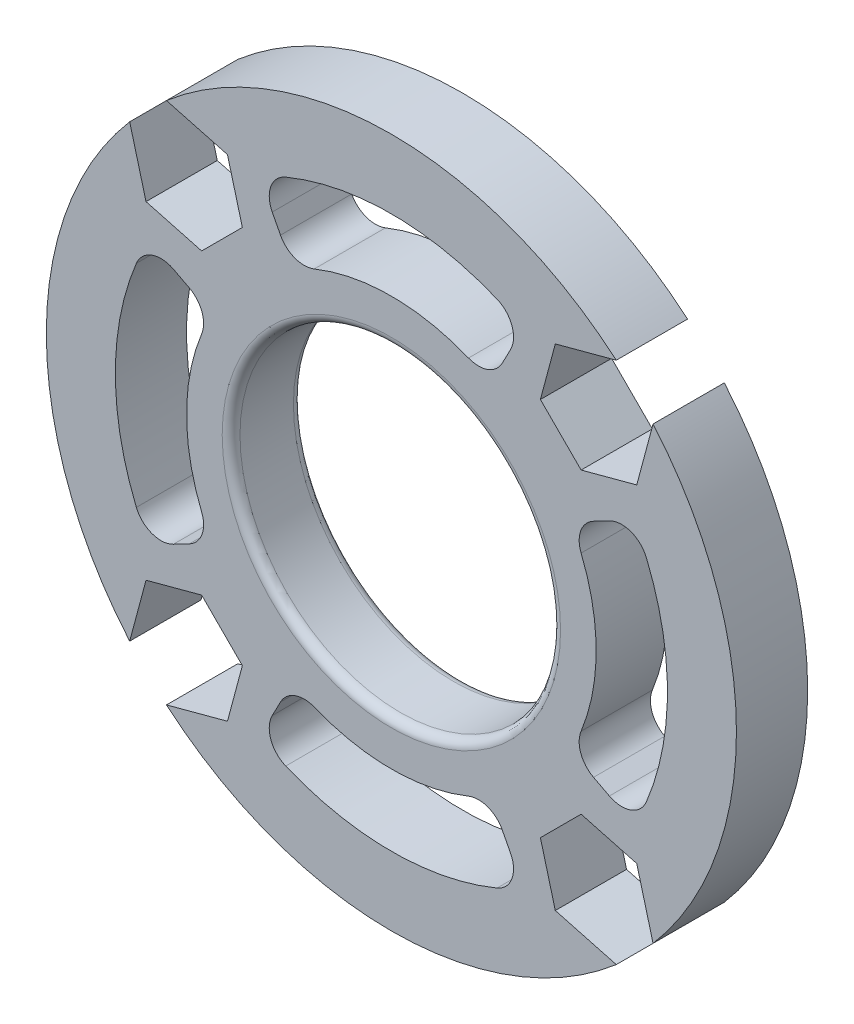
from build123d import *

# Parameters (mm, degrees)
SKETCH1_R           = 19.375
SKETCH1_R_2         = 9
BOSS_EXTRUDE1_DEPTH = 4
CUT_EXTRUDE1_DEPTH  = 4
FILLET1_R           = 0.5
CUT_EXTRUDE2_DEPTH  = 10


with BuildPart() as part:
    # Sketch1 → Boss-Extrude1 (new body)
    with BuildSketch(Plane.XY):
        Circle(SKETCH1_R)
        Circle(SKETCH1_R_2, mode=Mode.SUBTRACT)
        with BuildLine():
            Line((6.689691504, 12.241024694), (6.226047976, 11.350373764))
            ThreePointArc((6.226047976, 11.350373764), (5.41320923, 10.635157913), (4.330662681, 10.653420143))
            ThreePointArc((4.330662681, 10.653420143), (0, 11.5), (-4.330662681, 10.653420143))
            ThreePointArc((-4.330662681, 10.653420143), (-5.41320923, 10.635157913), (-6.226047976, 11.350373764))
            Line((-6.226047976, 11.350373764), (-6.689691504, 12.241024694))
            ThreePointArc((-6.689691504, 12.241024694), (-6.768746058, 13.446590252), (-5.933372603, 14.319395572))
            ThreePointArc((-5.933372603, 14.319395572), (0, 15.5), (5.933372603, 14.319395572))
            ThreePointArc((5.933372603, 14.319395572), (6.768746058, 13.446590252), (6.689691504, 12.241024694))
        make_face(mode=Mode.SUBTRACT)
        with BuildLine():
            Line((12.241024694, 6.689691504), (11.350373764, 6.226047976))
            ThreePointArc((11.350373764, 6.226047976), (10.635157913, 5.41320923), (10.653420143, 4.330662681))
            ThreePointArc((10.653420143, 4.330662681), (11.5, 0), (10.653420143, -4.330662681))
            ThreePointArc((10.653420143, -4.330662681), (10.635157913, -5.41320923), (11.350373764, -6.226047976))
            Line((11.350373764, -6.226047976), (12.241024694, -6.689691504))
            ThreePointArc((12.241024694, -6.689691504), (13.446590252, -6.768746058), (14.319395572, -5.933372603))
            ThreePointArc((14.319395572, -5.933372603), (15.5, 0), (14.319395572, 5.933372603))
            ThreePointArc((14.319395572, 5.933372603), (13.446590252, 6.768746058), (12.241024694, 6.689691504))
        make_face(mode=Mode.SUBTRACT)
        with BuildLine():
            Line((6.689691504, -12.241024694), (6.226047976, -11.350373764))
            ThreePointArc((6.226047976, -11.350373764), (5.41320923, -10.635157913), (4.330662681, -10.653420143))
            ThreePointArc((4.330662681, -10.653420143), (0, -11.5), (-4.330662681, -10.653420143))
            ThreePointArc((-4.330662681, -10.653420143), (-5.41320923, -10.635157913), (-6.226047976, -11.350373764))
            Line((-6.226047976, -11.350373764), (-6.689691504, -12.241024694))
            ThreePointArc((-6.689691504, -12.241024694), (-6.768746058, -13.446590252), (-5.933372603, -14.319395572))
            ThreePointArc((-5.933372603, -14.319395572), (0, -15.5), (5.933372603, -14.319395572))
            ThreePointArc((5.933372603, -14.319395572), (6.768746058, -13.446590252), (6.689691504, -12.241024694))
        make_face(mode=Mode.SUBTRACT)
        with BuildLine():
            Line((-12.241024694, -6.689691504), (-11.350373764, -6.226047976))
            ThreePointArc((-11.350373764, -6.226047976), (-10.635157913, -5.41320923), (-10.653420143, -4.330662681))
            ThreePointArc((-10.653420143, -4.330662681), (-11.5, 0), (-10.653420143, 4.330662681))
            ThreePointArc((-10.653420143, 4.330662681), (-10.635157913, 5.41320923), (-11.350373764, 6.226047976))
            Line((-11.350373764, 6.226047976), (-12.241024694, 6.689691504))
            ThreePointArc((-12.241024694, 6.689691504), (-13.446590252, 6.768746058), (-14.319395572, 5.933372603))
            ThreePointArc((-14.319395572, 5.933372603), (-15.5, 0), (-14.319395572, -5.933372603))
            ThreePointArc((-14.319395572, -5.933372603), (-13.446590252, -6.768746058), (-12.241024694, -6.689691504))
        make_face(mode=Mode.SUBTRACT)
    extrude(amount=BOSS_EXTRUDE1_DEPTH)

    # Sketch2 → Cut-Extrude1 (cut)
    with BuildSketch(Plane(origin=(0, 0, 0), x_dir=(-1, 0, 0), z_dir=(0, 0, -1))):
        Polygon((10.65368142, -8.367490994), (8.367490994, -10.65368142), (9.204294768, -13.776675621), (12.327288968, -14.613479395), (14.613479395, -12.327288968), (13.776675621, -9.204294768), align=None)
        Polygon((13.776675621, 9.204294768), (14.613479395, 12.327288968), (12.327288968, 14.613479395), (9.204294768, 13.776675621), (8.367490994, 10.65368142), (10.65368142, 8.367490994), align=None)
        Polygon((-8.367490994, -10.65368142), (-10.65368142, -8.367490994), (-13.776675621, -9.204294768), (-14.613479395, -12.327288968), (-12.327288968, -14.613479395), (-9.204294768, -13.776675621), align=None)
        Polygon((-10.65368142, 8.367490994), (-8.367490994, 10.65368142), (-9.204294768, 13.776675621), (-12.327288968, 14.613479395), (-14.613479395, 12.327288968), (-13.776675621, 9.204294768), align=None)
    extrude(amount=-CUT_EXTRUDE1_DEPTH, mode=Mode.SUBTRACT)

    # Fillet1
    fillet1_edges = [part.edges().sort_by_distance(p)[0] for p in [
        (-9, 0, 0),
        (-9, 0, 4),
    ]]
    fillet(fillet1_edges, radius=FILLET1_R)

    # Sketch3 → Cut-Extrude2 (cut)
    with BuildSketch(Plane.XY.offset(4)):
        Polygon((-13.776675621, 9.204294768), (-15.450283169, 15.450283169), (-9.204294768, 13.776675621), align=None)
        Polygon((9.204294768, 13.776675621), (15.450283169, 15.450283169), (13.776675621, 9.204294768), align=None)
        Polygon((13.776675621, -9.204294768), (15.450283169, -15.450283169), (9.204294768, -13.776675621), align=None)
        Polygon((-9.204294768, -13.776675621), (-15.450283169, -15.450283169), (-13.776675621, -9.204294768), align=None)
    extrude(amount=-CUT_EXTRUDE2_DEPTH, mode=Mode.SUBTRACT)


solid = part.part
